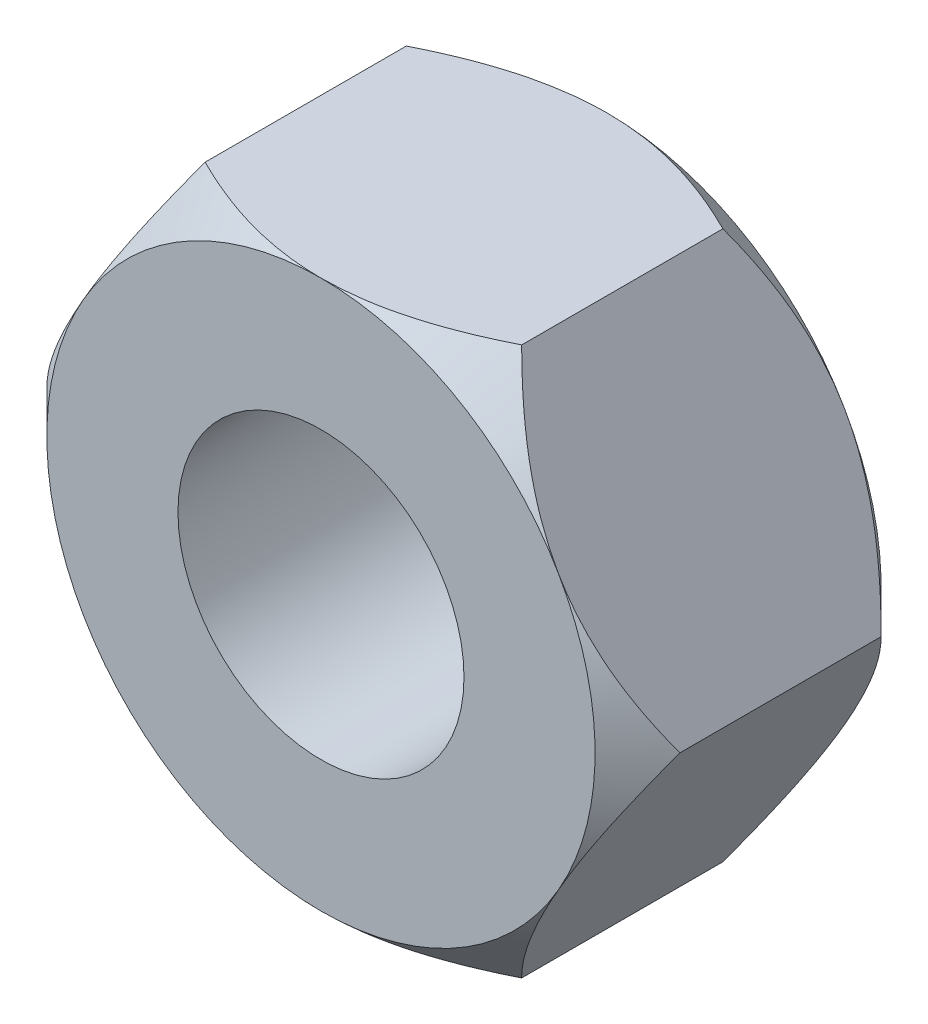
from build123d import *

# Parameters (mm, degrees)
SKETCH4_R           = 4.5
BOSS_EXTRUDE2_DEPTH = 4.5
SKETCH5_OUTSIDE_W   = 45.486
SKETCH5_OUTSIDE_H   = 42.818
SKETCH5_OUTSIDE_R   = 8.625
CUT_EXTRUDE2_DEPTH  = 9
CUT_EXTRUDE2_TAPER  = 45


with BuildPart() as part:
    # Sketch4 → Boss-Extrude2 (new body, symmetric)
    with BuildSketch(Plane.XY):
        Polygon((9.959292144, 0), (4.979646072, 8.625), (-4.979646072, 8.625), (-9.959292144, 0), (-4.979646072, -8.625), (4.979646072, -8.625), align=None)
        Circle(SKETCH4_R, mode=Mode.SUBTRACT)
    extrude(amount=BOSS_EXTRUDE2_DEPTH, both=True)

    # Sketch5 outside → Cut-Extrude2 (cut)
    with BuildSketch(Plane.XY.offset(4.5)):
        Rectangle(SKETCH5_OUTSIDE_W, SKETCH5_OUTSIDE_H)
        Circle(SKETCH5_OUTSIDE_R, mode=Mode.SUBTRACT)
    cut_extrude2 = extrude(amount=-CUT_EXTRUDE2_DEPTH, taper=CUT_EXTRUDE2_TAPER, mode=Mode.SUBTRACT)

    # Mirror1: Cut-Extrude2 across plane
    add(cut_extrude2.mirror(Plane.XY), mode=Mode.SUBTRACT)


solid = part.part
